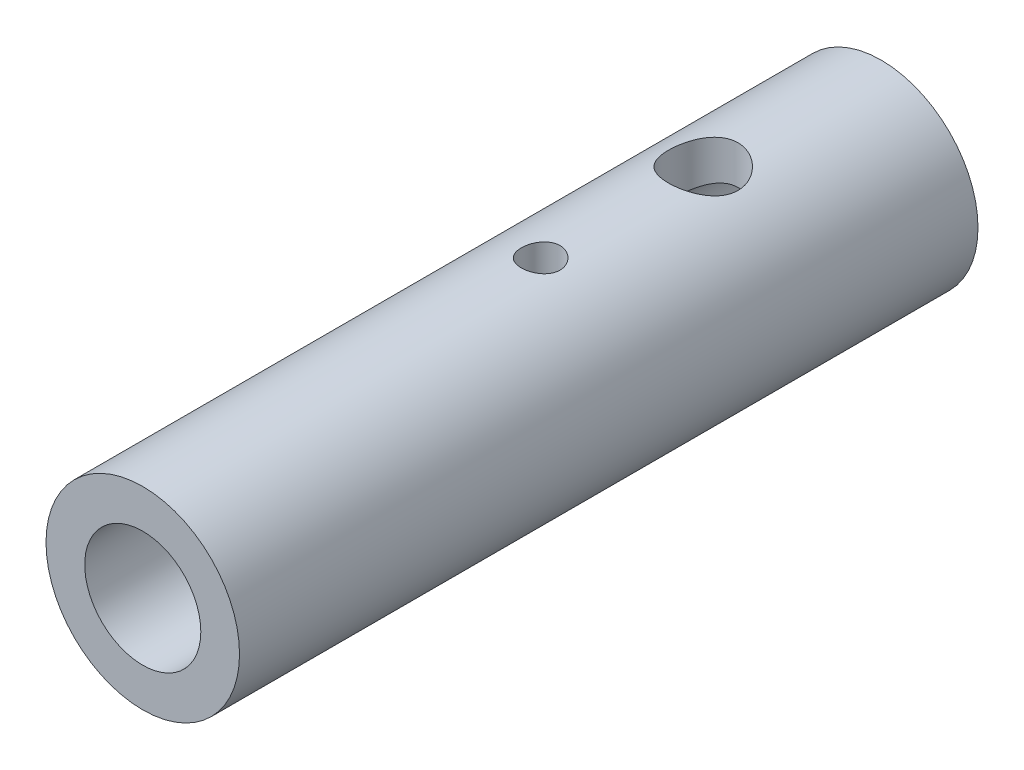
from build123d import *

# Parameters (mm, degrees)
SKETCH1_R               = 7.9375
SKETCH1_R_2             = 4.7625
BOSS_EXTRUDE1_DEPTH     = 60.579
CUT_EXTRUDE1_DEPTH      = 60.579
CUT_EXTRUDE1_DEPTH_BACK = 60.579
SKETCH2_R               = 2.8575
CUT_EXTRUDE2_DEPTH      = 60.579
CUT_EXTRUDE2_DEPTH_BACK = 60.579
SKETCH3_R               = 1.5875


with BuildPart() as part:
    # Sketch1 → Boss-Extrude1 (new body)
    with BuildSketch(Plane.XY):
        Circle(SKETCH1_R)
        Circle(SKETCH1_R_2, mode=Mode.SUBTRACT)
    extrude(amount=BOSS_EXTRUDE1_DEPTH)

    # Sketch2 → Cut-Extrude1 (cut, two sides: drawn at the far end of the back side and taken through both)
    with BuildSketch(Plane(origin=(0, 0, 0), x_dir=(1, 0, 0), z_dir=(0, 1, 0)).offset(-CUT_EXTRUDE1_DEPTH_BACK)):
        with Locations((0, -14.605)):
            Circle(SKETCH2_R)
    extrude(amount=CUT_EXTRUDE1_DEPTH + CUT_EXTRUDE1_DEPTH_BACK, mode=Mode.SUBTRACT)

    # Sketch3 → Cut-Extrude2 (cut, two sides: drawn at the far end of the back side and taken through both)
    with BuildSketch(Plane(origin=(0, 0, 0), x_dir=(1, 0, 0), z_dir=(0, 1, 0)).offset(-CUT_EXTRUDE2_DEPTH_BACK)):
        with Locations((0, -27.94)):
            Circle(SKETCH3_R)
    extrude(amount=CUT_EXTRUDE2_DEPTH + CUT_EXTRUDE2_DEPTH_BACK, mode=Mode.SUBTRACT)


solid = part.part
